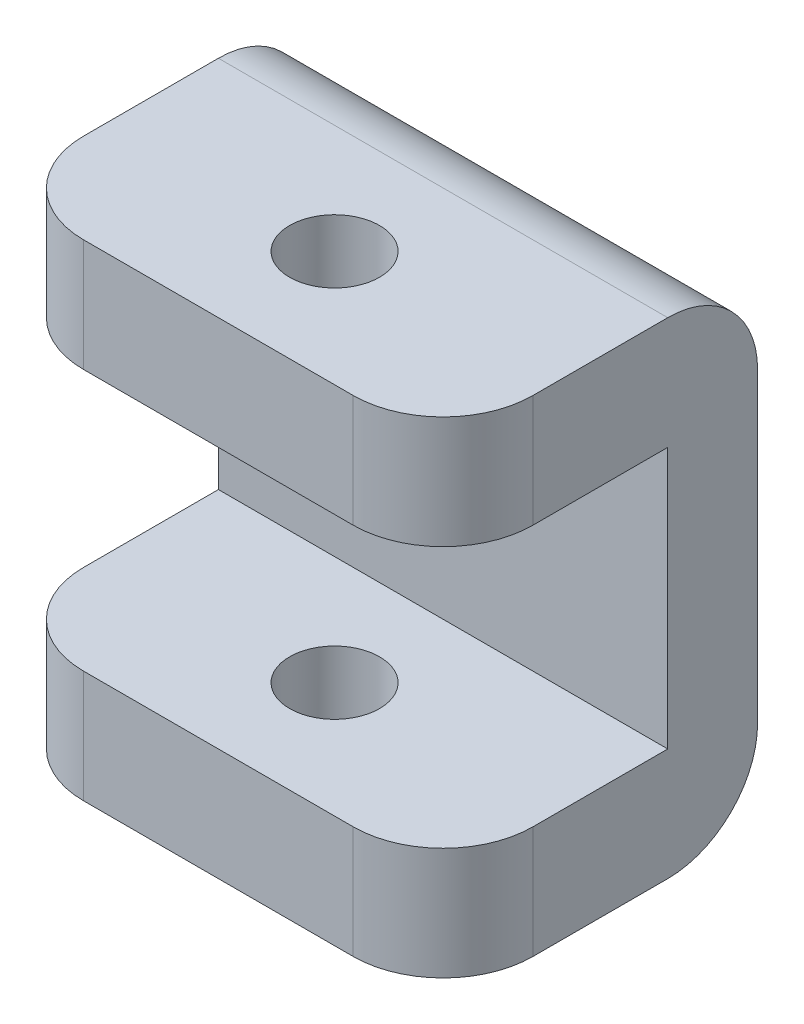
from build123d import *

# Parameters (mm, degrees)
SKETCH1_W           = 10
SKETCH1_H           = 10.813
BOSS_EXTRUDE1_DEPTH = 2
SKETCH2_W           = 10
SKETCH2_H           = 2.5
BOSS_EXTRUDE2_DEPTH = 5
SKETCH3_R           = 1
CUT_EXTRUDE1_DEPTH  = 11.813
FILLET2_R           = 2


with BuildPart() as part:
    # Sketch1 → Boss-Extrude1 (new body)
    with BuildSketch(Plane.XY):
        with Locations((-3.333333333, -1.47534058)):
            Rectangle(SKETCH1_W, SKETCH1_H)
    extrude(amount=BOSS_EXTRUDE1_DEPTH)

    # Sketch2 → Boss-Extrude2 (add)
    with BuildSketch(Plane.XY.offset(2)):
        with Locations((-3.333333333, 2.68115942)):
            Rectangle(SKETCH2_W, SKETCH2_H)
        with Locations((-3.333333333, -5.63184058)):
            Rectangle(SKETCH2_W, SKETCH2_H)
    extrude(amount=BOSS_EXTRUDE2_DEPTH)

    # Sketch3 → Cut-Extrude1 (cut, through all)
    with BuildSketch(Plane(origin=(0, 3.93115942, 0), x_dir=(1, 0, 0), z_dir=(0, 1, 0))):
        with Locations((-3.318584334, -4.43)):
            Circle(SKETCH3_R)
    extrude(amount=-CUT_EXTRUDE1_DEPTH, mode=Mode.SUBTRACT)

    # Fillet2
    fillet2_edges = [part.edges().sort_by_distance(p)[0] for p in [
        (-8.333333333, 2.68115942, 7),
        (1.666666667, 2.68115942, 7),
        (1.666666667, -5.63184058, 7),
        (-8.333333333, -5.63184058, 7),
        (-3.333333333, 3.93115942, 0),
        (-3.333333333, -6.88184058, 0),
    ]]
    fillet(fillet2_edges, radius=FILLET2_R)


solid = part.part
